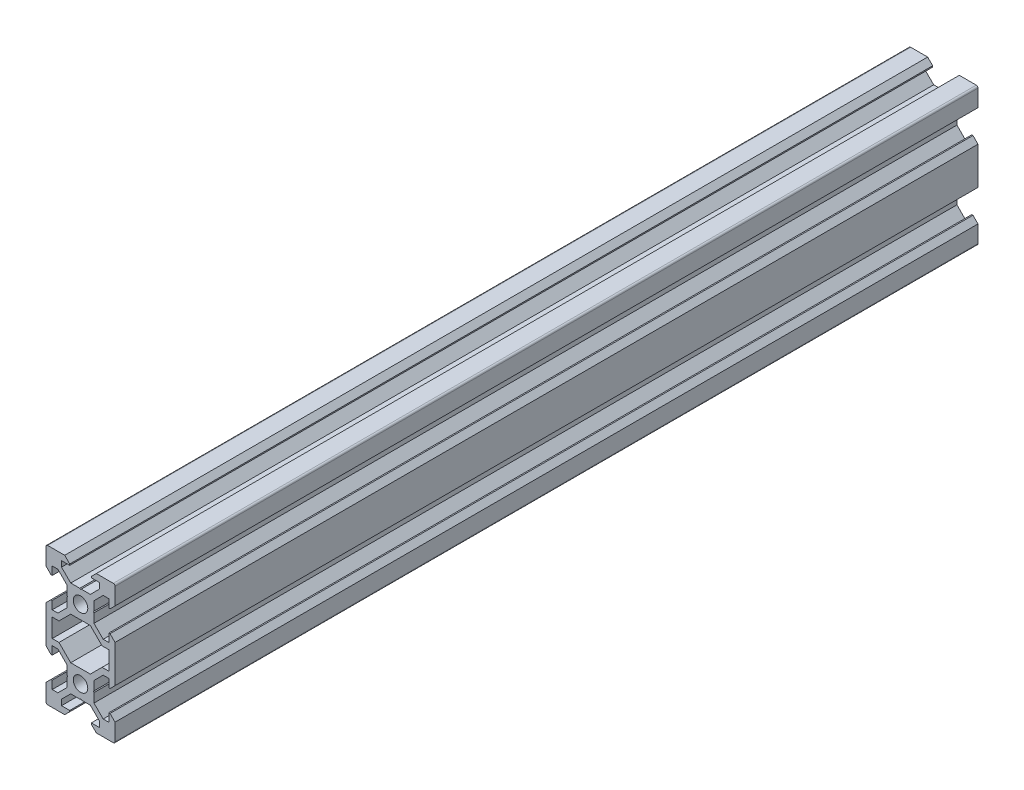
from build123d import *

# Parameters (mm, degrees)
SKETCH1_R           = 2.1
BOSS_EXTRUDE1_DEPTH = 250


with BuildPart() as part:
    # Sketch1 → Boss-Extrude1 (new body)
    with BuildSketch(Plane.XY):
        with BuildLine():
            Line((4.58, -20), (9.5, -20))
            ThreePointArc((9.5, -20), (9.853553391, -19.853553391), (10, -19.5))
            Line((10, -19.5), (10, -14.58))
            Line((10, -14.58), (8.545, -13.125))
            Line((8.545, -13.125), (8.2, -13.125))
            Line((8.2, -13.125), (8.2, -15.5))
            Line((8.2, -15.5), (6.560660172, -15.5))
            Line((6.560660172, -15.5), (3.9, -12.839339828))
            Line((3.9, -12.839339828), (3.9, -10.21))
            Line((3.9, -10.21), (3.69, -10))
            Line((3.69, -10), (3.9, -9.79))
            Line((3.9, -9.79), (3.9, -7.160660172))
            Line((3.9, -7.160660172), (6.560660172, -4.5))
            Line((6.560660172, -4.5), (8.2, -4.5))
            Line((8.2, -4.5), (8.2, -6.875))
            Line((8.2, -6.875), (8.545, -6.875))
            Line((8.545, -6.875), (10, -5.42))
            Line((10, -5.42), (10, 5.42))
            Line((10, 5.42), (8.545, 6.875))
            Line((8.545, 6.875), (8.2, 6.875))
            Line((8.2, 6.875), (8.2, 4.5))
            Line((8.2, 4.5), (6.560660172, 4.5))
            Line((6.560660172, 4.5), (3.9, 7.160660172))
            Line((3.9, 7.160660172), (3.9, 9.79))
            Line((3.9, 9.79), (3.69, 10))
            Line((3.69, 10), (3.9, 10.21))
            Line((3.9, 10.21), (3.9, 12.839339828))
            Line((3.9, 12.839339828), (6.560660172, 15.5))
            Line((6.560660172, 15.5), (8.2, 15.5))
            Line((8.2, 15.5), (8.2, 13.125))
            Line((8.2, 13.125), (8.545, 13.125))
            Line((8.545, 13.125), (10, 14.58))
            Line((10, 14.58), (10, 19.5))
            ThreePointArc((10, 19.5), (9.853553391, 19.853553391), (9.5, 20))
            Line((9.5, 20), (4.58, 20))
            Line((4.58, 20), (3.125, 18.545))
            Line((3.125, 18.545), (3.125, 18.2))
            Line((3.125, 18.2), (5.5, 18.2))
            Line((5.5, 18.2), (5.5, 16.560660172))
            Line((5.5, 16.560660172), (2.839339828, 13.9))
            Line((2.839339828, 13.9), (0.21, 13.9))
            Line((0.21, 13.9), (0, 13.69))
            Line((0, 13.69), (-0.21, 13.9))
            Line((-0.21, 13.9), (-2.839339828, 13.9))
            Line((-2.839339828, 13.9), (-5.5, 16.560660172))
            Line((-5.5, 16.560660172), (-5.5, 18.2))
            Line((-5.5, 18.2), (-3.125, 18.2))
            Line((-3.125, 18.2), (-3.125, 18.545))
            Line((-3.125, 18.545), (-4.58, 20))
            Line((-4.58, 20), (-9.5, 20))
            ThreePointArc((-9.5, 20), (-9.853553391, 19.853553391), (-10, 19.5))
            Line((-10, 19.5), (-10, 14.58))
            Line((-10, 14.58), (-8.545, 13.125))
            Line((-8.545, 13.125), (-8.2, 13.125))
            Line((-8.2, 13.125), (-8.2, 15.5))
            Line((-8.2, 15.5), (-6.560660172, 15.5))
            Line((-6.560660172, 15.5), (-3.9, 12.839339828))
            Line((-3.9, 12.839339828), (-3.9, 10.21))
            Line((-3.9, 10.21), (-3.69, 10))
            Line((-3.69, 10), (-3.9, 9.79))
            Line((-3.9, 9.79), (-3.9, 7.160660172))
            Line((-3.9, 7.160660172), (-6.560660172, 4.5))
            Line((-6.560660172, 4.5), (-8.2, 4.5))
            Line((-8.2, 4.5), (-8.2, 6.875))
            Line((-8.2, 6.875), (-8.545, 6.875))
            Line((-8.545, 6.875), (-10, 5.42))
            Line((-10, 5.42), (-10, -5.42))
            Line((-10, -5.42), (-8.545, -6.875))
            Line((-8.545, -6.875), (-8.2, -6.875))
            Line((-8.2, -6.875), (-8.2, -4.5))
            Line((-8.2, -4.5), (-6.560660172, -4.5))
            Line((-6.560660172, -4.5), (-3.9, -7.160660172))
            Line((-3.9, -7.160660172), (-3.9, -9.79))
            Line((-3.9, -9.79), (-3.69, -10))
            Line((-3.69, -10), (-3.9, -10.21))
            Line((-3.9, -10.21), (-3.9, -12.839339828))
            Line((-3.9, -12.839339828), (-6.560660172, -15.5))
            Line((-6.560660172, -15.5), (-8.2, -15.5))
            Line((-8.2, -15.5), (-8.2, -13.125))
            Line((-8.2, -13.125), (-8.545, -13.125))
            Line((-8.545, -13.125), (-10, -14.58))
            Line((-10, -14.58), (-10, -19.5))
            ThreePointArc((-10, -19.5), (-9.853553391, -19.853553391), (-9.5, -20))
            Line((-9.5, -20), (-4.58, -20))
            Line((-4.58, -20), (-3.125, -18.545))
            Line((-3.125, -18.545), (-3.125, -18.2))
            Line((-3.125, -18.2), (-5.5, -18.2))
            Line((-5.5, -18.2), (-5.5, -16.560660172))
            Line((-5.5, -16.560660172), (-2.839339828, -13.9))
            Line((-2.839339828, -13.9), (-0.21, -13.9))
            Line((-0.21, -13.9), (0, -13.69))
            Line((0, -13.69), (0.21, -13.9))
            Line((0.21, -13.9), (2.839339828, -13.9))
            Line((2.839339828, -13.9), (5.5, -16.560660172))
            Line((5.5, -16.560660172), (5.5, -18.2))
            Line((5.5, -18.2), (3.125, -18.2))
            Line((3.125, -18.2), (3.125, -18.545))
            Line((3.125, -18.545), (4.58, -20))
        make_face()
        with Locations((0, -10)):
            Circle(SKETCH1_R, mode=Mode.SUBTRACT)
        Polygon((-6.239339828, -2.7), (-8.2, -2.7), (-8.2, 2.7), (-6.239339828, 2.7), (-2.839339828, 6.1), (2.839339828, 6.1), (6.239339828, 2.7), (8.2, 2.7), (8.2, -2.7), (6.239339828, -2.7), (2.839339828, -6.1), (-2.839339828, -6.1), align=None, mode=Mode.SUBTRACT)
        with Locations((0, 10)):
            Circle(SKETCH1_R, mode=Mode.SUBTRACT)
    extrude(amount=BOSS_EXTRUDE1_DEPTH)


solid = part.part
